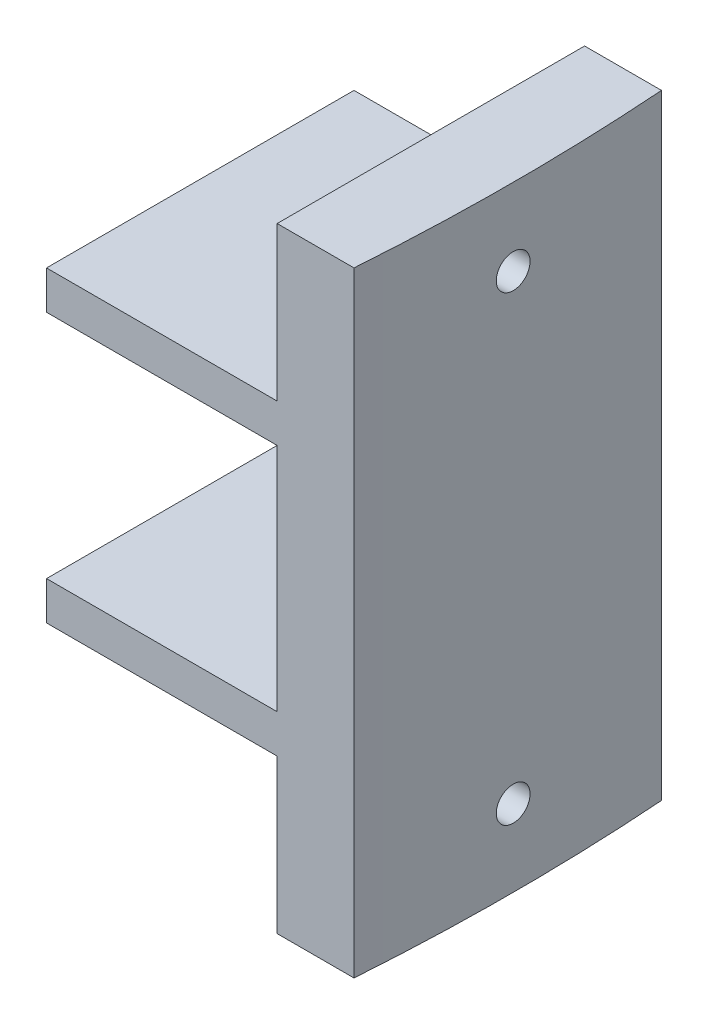
from build123d import *

# Parameters (mm, degrees)
SKETCH1_R                = 1.1303
BOSS_EXTRUDE1_DEPTH      = 12.7
SKETCH2_W                = 9.525
SKETCH2_H                = 9.525
CUT_EXTRUDE1_DEPTH       = 13.7
BOSS_EXTRUDE2_DEPTH      = 6.35
BOSS_EXTRUDE2_DEPTH_BACK = 19.05
SKETCH5_R                = 0.6985
CUT_EXTRUDE2_DEPTH       = 4.402075722


with BuildPart() as part:
    # Sketch1 → Boss-Extrude1 (new body)
    with BuildSketch(Plane(origin=(0, 0, 0), x_dir=(1, 0, 0), z_dir=(0, 1, 0))):
        with BuildLine():
            Line((75.972924278, -6.35), (88.672924278, -6.35))
            ThreePointArc((88.672924278, -6.35), (88.9, 0), (88.672924278, 6.35))
            Line((88.672924278, 6.35), (75.972924278, 6.35))
            Line((75.972924278, 6.35), (75.972924278, -6.35))
        make_face()
        with Locations((82.322924278, 0)):
            Circle(SKETCH1_R, mode=Mode.SUBTRACT)
    extrude(amount=BOSS_EXTRUDE1_DEPTH)

    # Sketch2 → Cut-Extrude1 (cut, through all)
    with BuildSketch(Plane.XY.offset(6.35)):
        with Locations((80.735424278, 6.35)):
            Rectangle(SKETCH2_W, SKETCH2_H)
    extrude(amount=-CUT_EXTRUDE1_DEPTH, mode=Mode.SUBTRACT)

    # Sketch3 → Boss-Extrude2 (add, two sides)
    with BuildSketch(Plane(origin=(0, 12.7, 0), x_dir=(1, 0, 0), z_dir=(0, 1, 0))) as boss_extrude2_sk:
        with BuildLine():
            Line((85.497924278, -6.35), (88.672924278, -6.35))
            ThreePointArc((88.672924278, -6.35), (88.9, 0), (88.672924278, 6.35))
            Line((88.672924278, 6.35), (85.497924278, 6.35))
            Line((85.497924278, 6.35), (85.497924278, -6.35))
        make_face()
    extrude(amount=BOSS_EXTRUDE2_DEPTH)
    extrude(boss_extrude2_sk.sketch, amount=-BOSS_EXTRUDE2_DEPTH_BACK)

    # Sketch5 → Cut-Extrude2 (cut, through all)
    with BuildSketch(Plane.ZY.offset(-85.497924278)):
        with Locations((0, 15.875)):
            Circle(SKETCH5_R)
        with Locations((0, -3.175)):
            Circle(SKETCH5_R)
    extrude(amount=-CUT_EXTRUDE2_DEPTH, mode=Mode.SUBTRACT)


solid = part.part
